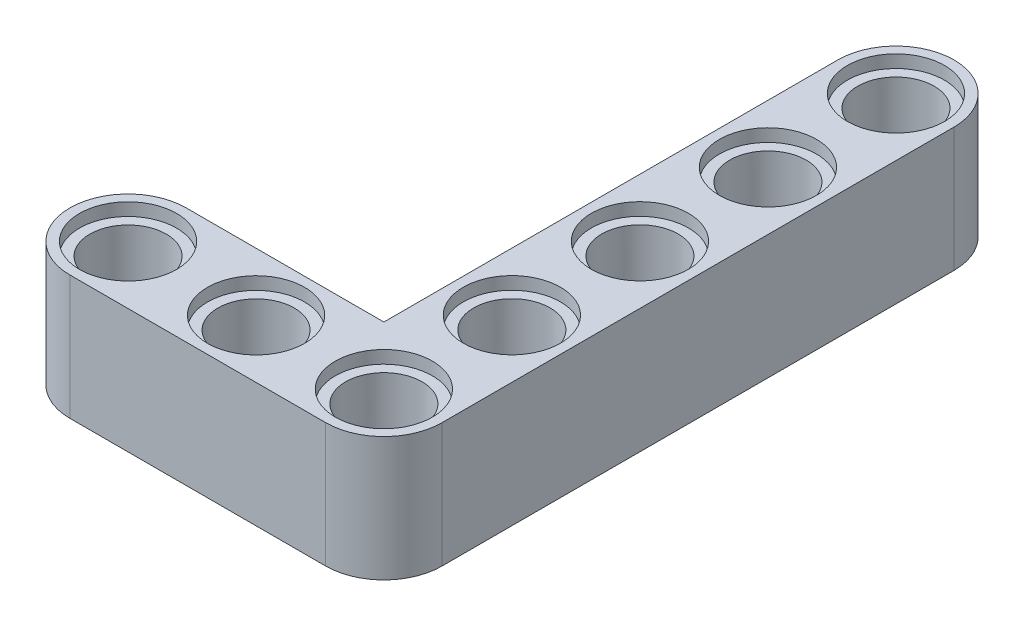
from build123d import *

# Parameters (mm, degrees)
SKETCH1_R           = 2.4
BOSS_EXTRUDE1_DEPTH = 7.8
SKETCH2_R           = 3.05
CUT_EXTRUDE1_DEPTH  = 0.8
SKETCH3_R           = 3.05
CUT_EXTRUDE2_DEPTH  = 0.8


with BuildPart() as part:
    # Sketch1 → Boss-Extrude1 (new body)
    with BuildSketch(Plane(origin=(0, 0, 0), x_dir=(1, 0, 0), z_dir=(0, 1, 0))):
        with BuildLine():
            Line((-39.012427485, -14.890555083), (-26.596473565, -14.89055472))
            Line((-26.596473565, -14.89055472), (-26.596474399, 13.619444917))
            ThreePointArc((-26.596474399, 13.619444917), (-22.946475341, 17.269443976), (-19.296476282, 13.619444917))
            Line((-19.296476282, 13.619444917), (-19.296475341, -18.540555083))
            ThreePointArc((-19.296475341, -18.540555083), (-20.365535589, -21.121494834), (-22.946475341, -22.190555083))
            Line((-22.946475341, -22.190555083), (-39.012427485, -22.190555083))
            ThreePointArc((-39.012427485, -22.190555083), (-42.662427485, -18.540555083), (-39.012427485, -14.890555083))
        make_face()
        with Locations((-39.012427485, -18.540555083)):
            Circle(SKETCH1_R, mode=Mode.SUBTRACT)
        with Locations((-30.972427485, -18.540555083)):
            Circle(SKETCH1_R, mode=Mode.SUBTRACT)
        with Locations((-22.946475341, -18.540555083)):
            Circle(SKETCH1_R, mode=Mode.SUBTRACT)
        with Locations((-22.946475341, 13.619444917)):
            Circle(SKETCH1_R, mode=Mode.SUBTRACT)
        with Locations((-22.946475341, 5.579444917)):
            Circle(SKETCH1_R, mode=Mode.SUBTRACT)
        with Locations((-22.946475341, -2.460555083)):
            Circle(SKETCH1_R, mode=Mode.SUBTRACT)
        with Locations((-22.946475341, -10.500555083)):
            Circle(SKETCH1_R, mode=Mode.SUBTRACT)
    extrude(amount=BOSS_EXTRUDE1_DEPTH)

    # Sketch2 → Cut-Extrude1 (cut)
    with BuildSketch(Plane(origin=(0, 7.8, 0), x_dir=(1, 0, 0), z_dir=(0, 1, 0))):
        with Locations((-39.012427485, -18.540555083)):
            Circle(SKETCH2_R)
        with Locations((-30.972427485, -18.540555083)):
            Circle(SKETCH2_R)
        with Locations((-22.946475341, -18.540555083)):
            Circle(SKETCH2_R)
        with Locations((-22.946475341, -10.500555083)):
            Circle(SKETCH2_R)
        with Locations((-22.946475341, -2.460555083)):
            Circle(SKETCH2_R)
        with Locations((-22.946475341, 5.579444917)):
            Circle(SKETCH2_R)
        with Locations((-22.946475341, 13.619444917)):
            Circle(SKETCH2_R)
    extrude(amount=-CUT_EXTRUDE1_DEPTH, mode=Mode.SUBTRACT)

    # Sketch3 → Cut-Extrude2 (cut)
    with BuildSketch(Plane.XZ):
        with Locations((-30.972427485, 18.540555083)):
            Circle(SKETCH3_R)
        with Locations((-39.012427485, 18.540555083)):
            Circle(SKETCH3_R)
        with Locations((-22.946475341, 18.540555083)):
            Circle(SKETCH3_R)
        with Locations((-22.946475341, 10.500555083)):
            Circle(SKETCH3_R)
        with Locations((-22.946475341, 2.460555083)):
            Circle(SKETCH3_R)
        with Locations((-22.946475341, -5.579444917)):
            Circle(SKETCH3_R)
        with Locations((-22.946475341, -13.619444917)):
            Circle(SKETCH3_R)
    extrude(amount=-CUT_EXTRUDE2_DEPTH, mode=Mode.SUBTRACT)


solid = part.part
